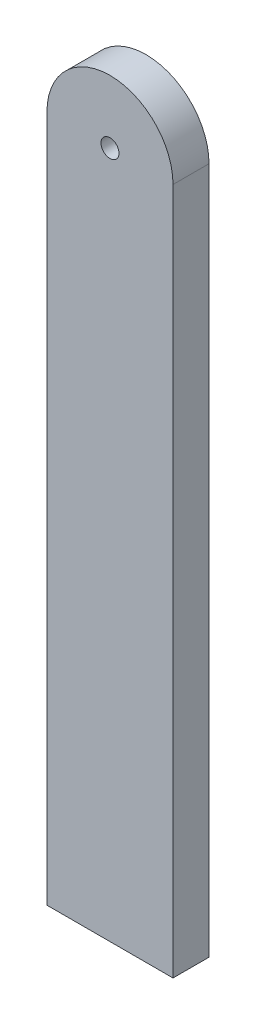
from build123d import *

# Parameters (mm, degrees)
SKETCH1_R           = 4.7625
BOSS_EXTRUDE1_DEPTH = 9.525


with BuildPart() as part:
    # Sketch1 → Boss-Extrude1 (new body, symmetric)
    with BuildSketch(Plane.XY):
        with BuildLine():
            Line((33.3375, -198.4375), (-33.3375, -198.4375))
            Line((-33.3375, -198.4375), (-33.3375, 165.1))
            ThreePointArc((-33.3375, 165.1), (0, 198.4375), (33.3375, 165.1))
            Line((33.3375, 165.1), (33.3375, -198.4375))
        make_face()
        with Locations((0, 165.1)):
            Circle(SKETCH1_R, mode=Mode.SUBTRACT)
    extrude(amount=BOSS_EXTRUDE1_DEPTH, both=True)


solid = part.part
